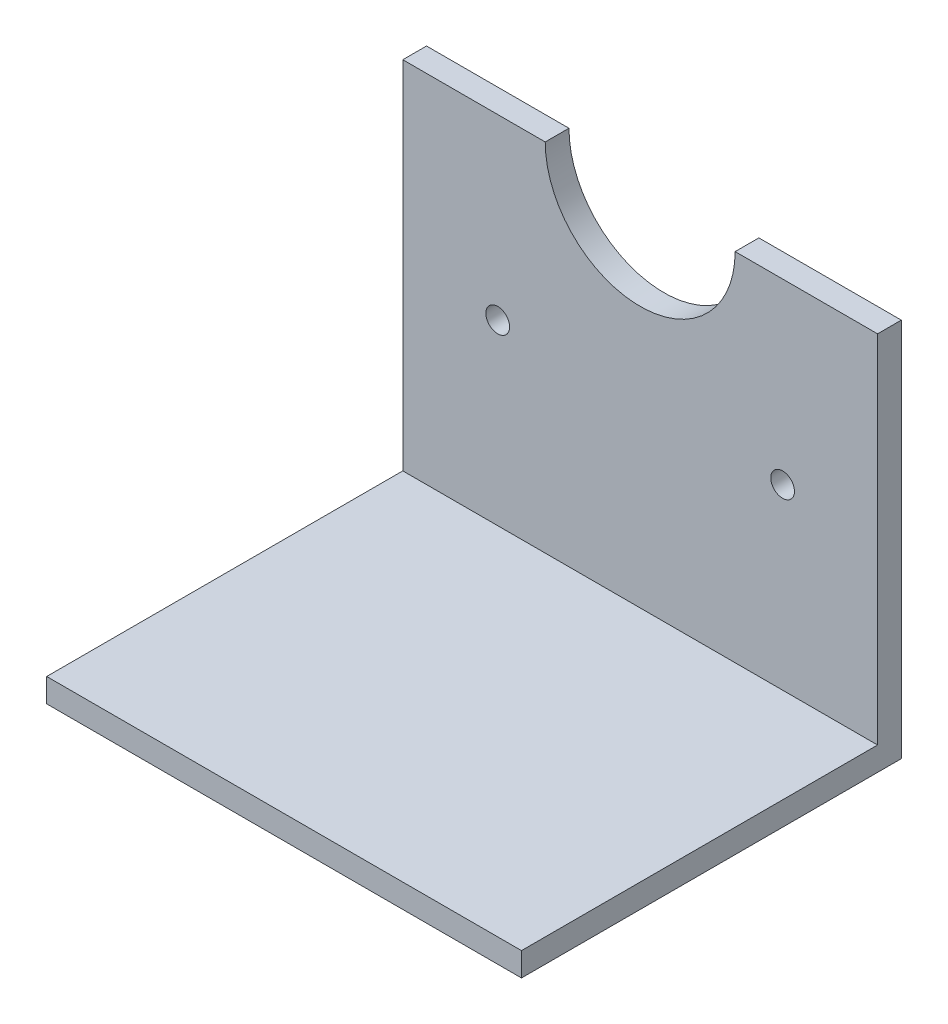
from build123d import *

# Parameters (mm, degrees)
BOSS_EXTRUDE1_DEPTH = 63.5
SKETCH2_R           = 12.7
SKETCH2_R_2         = 1.5875
CUT_EXTRUDE1_DEPTH  = 3.175


with BuildPart() as part:
    # Sketch1 → Boss-Extrude1 (new body)
    with BuildSketch(Plane(origin=(0, 0, 0), x_dir=(0, 0, -1), z_dir=(1, 0, 0))):
        Polygon((-3.175, 0), (-50.8, 0), (-50.8, -3.175), (0, -3.175), (0, 0), (0, 47.625), (-3.175, 47.625), align=None)
    extrude(amount=BOSS_EXTRUDE1_DEPTH)

    # Sketch2 → Cut-Extrude1 (cut)
    with BuildSketch(Plane.XY.offset(3.175)):
        with Locations((31.75, 47.625)):
            Circle(SKETCH2_R)
        with Locations((12.7, 23.8125)):
            Circle(SKETCH2_R_2)
        with Locations((50.8, 23.8125)):
            Circle(SKETCH2_R_2)
    extrude(amount=-CUT_EXTRUDE1_DEPTH, mode=Mode.SUBTRACT)


solid = part.part
